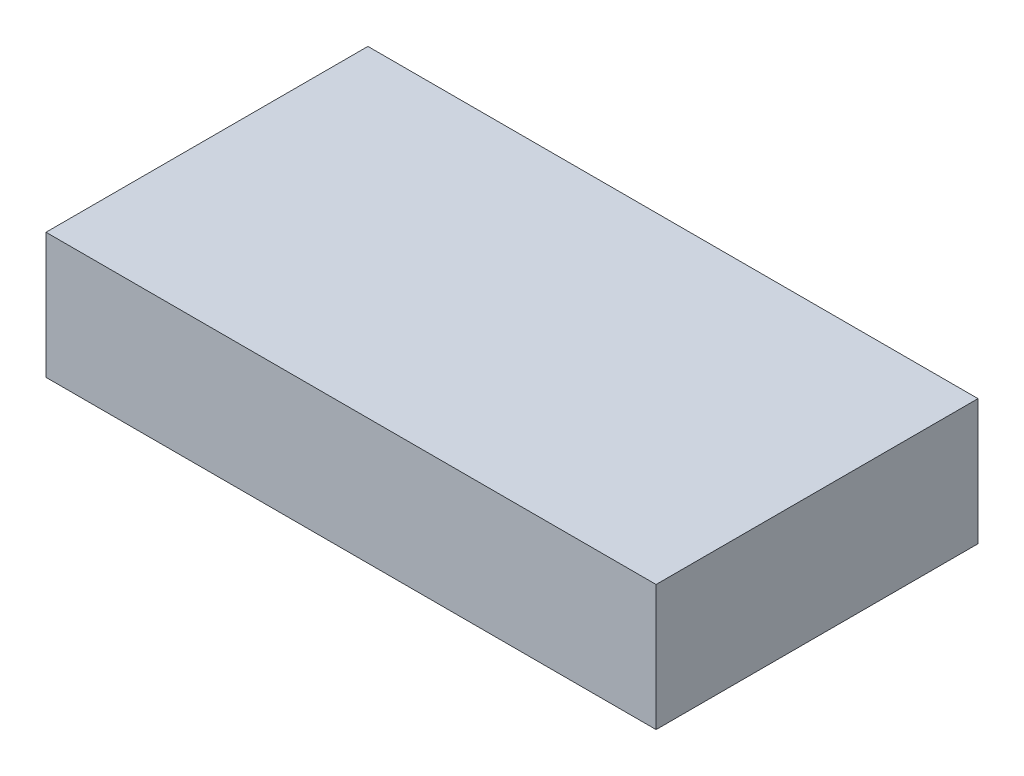
from build123d import *

# Parameters (mm, degrees)
SKETCH1_W           = 199
SKETCH1_H           = 105
BOSS_EXTRUDE1_DEPTH = 41


with BuildPart() as part:
    # Sketch1 → Boss-Extrude1 (new body)
    with BuildSketch(Plane(origin=(0, 0, 0), x_dir=(1, 0, 0), z_dir=(0, 1, 0))):
        Rectangle(SKETCH1_W, SKETCH1_H)
    extrude(amount=BOSS_EXTRUDE1_DEPTH)


solid = part.part
